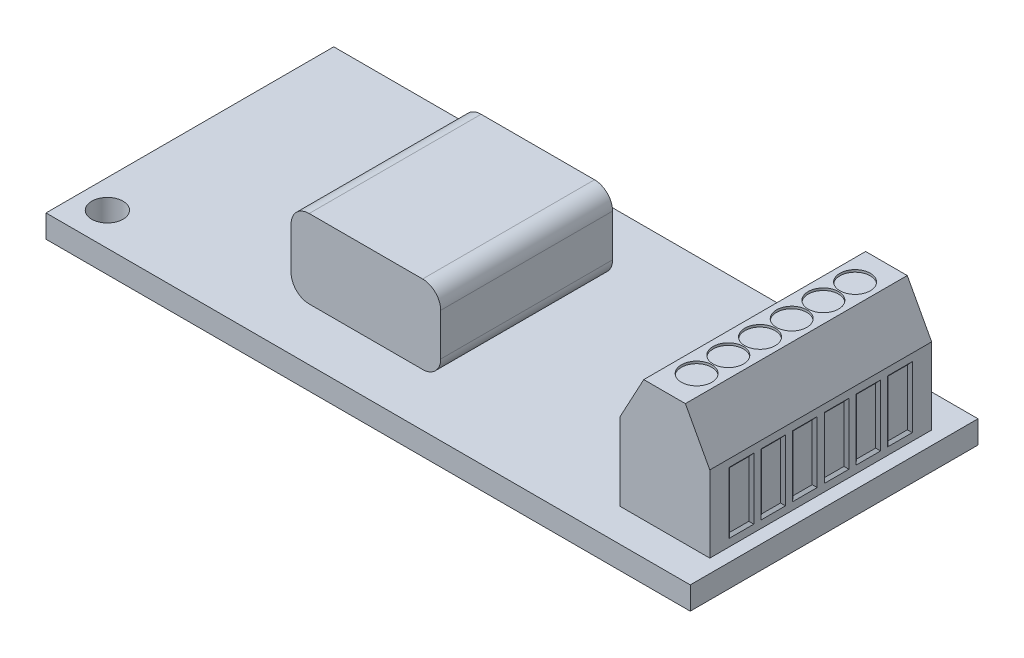
from build123d import *

# Parameters (mm, degrees)
SKETCH1_W           = 45.212
SKETCH1_H           = 20.193
BOSS_EXTRUDE1_DEPTH = 0.8001
SKETCH2_W           = 6.2992
SKETCH2_H           = 15.5702
BOSS_EXTRUDE2_DEPTH = 8.5344
SKETCH6_R           = 1.1
CUT_EXTRUDE4_DEPTH  = 2.6002
SKETCH7_W           = 10.5
SKETCH7_H           = 12.063
BOSS_EXTRUDE3_DEPTH = 5.5
CUT_EXTRUDE5_DEPTH  = 18.8816
SKETCH4_R           = 1.0668
CUT_EXTRUDE6_DEPTH  = 0.15875
SKETCH5_W           = 1.7272
SKETCH5_H           = 4.318
CUT_EXTRUDE7_DEPTH  = 0.15875
CUT_EXTRUDE7_TAPER  = 50
FILLET1_R           = 1.27
SKETCH8_W           = 5
SKETCH8_H           = 5
BOSS_EXTRUDE4_DEPTH = 2.17


with BuildPart() as part:
    # Sketch1 → Boss-Extrude1 (new body, symmetric)
    with BuildSketch(Plane(origin=(0, 0, 0), x_dir=(1, 0, 0), z_dir=(0, 1, 0))):
        Rectangle(SKETCH1_W, SKETCH1_H)
    extrude(amount=BOSS_EXTRUDE1_DEPTH, both=True)

    # Sketch6 → Cut-Extrude4 (cut, through all)
    with BuildSketch(Plane(origin=(0, 0.8001, 0), x_dir=(1, 0, 0), z_dir=(0, 1, 0))):
        with Locations((-20.617, -7.7773)):
            Circle(SKETCH6_R)
        with Locations((11.806, 7.7465)):
            Circle(SKETCH6_R)
    extrude(amount=-CUT_EXTRUDE4_DEPTH, mode=Mode.SUBTRACT)


with BuildPart() as body_2:
    # Sketch2 → Boss-Extrude2 (new body)
    with BuildSketch(Plane(origin=(0, 0.8001, 0), x_dir=(1, 0, 0), z_dir=(0, 1, 0))):
        with Locations((18.5166, 0)):
            Rectangle(SKETCH2_W, SKETCH2_H)
    extrude(amount=BOSS_EXTRUDE2_DEPTH)

    # Sketch3 → Cut-Extrude5 (cut, through all)
    with BuildSketch(Plane.XY.offset(7.7851)):
        Polygon((17.031947663, 9.3345), (19.952947663, 9.3345), (21.6662, 6.1595), (21.6662, 11.226261879), (15.318695326, 11.226261879), (15.318695326, 6.1595), align=None)
    extrude(amount=-CUT_EXTRUDE5_DEPTH, mode=Mode.SUBTRACT)

    # Sketch4 → Cut-Extrude6 (cut)
    with BuildSketch(Plane(origin=(0, 9.3345, 0), x_dir=(1, 0, 0), z_dir=(0, 1, 0))):
        with Locations((18.5166, -5.560785714)):
            Circle(SKETCH4_R)
        with Locations((18.5166, -3.336471429)):
            Circle(SKETCH4_R)
        with Locations((18.5166, -1.112157143)):
            Circle(SKETCH4_R)
        with Locations((18.5166, 1.112157143)):
            Circle(SKETCH4_R)
        with Locations((18.5166, 3.336471429)):
            Circle(SKETCH4_R)
        with Locations((18.5166, 5.560785714)):
            Circle(SKETCH4_R)
    extrude(amount=-CUT_EXTRUDE6_DEPTH, mode=Mode.SUBTRACT)

    # Sketch5 → Cut-Extrude7 (cut)
    with BuildSketch(Plane(origin=(21.6662, 0, 0), x_dir=(0, 0, -1), z_dir=(1, 0, 0))):
        with Locations((-5.560785714, 3.4798)):
            Rectangle(SKETCH5_W, SKETCH5_H)
        with Locations((-3.336471429, 3.4798)):
            Rectangle(SKETCH5_W, SKETCH5_H)
        with Locations((-1.112157143, 3.4798)):
            Rectangle(SKETCH5_W, SKETCH5_H)
        with Locations((1.112157143, 3.4798)):
            Rectangle(SKETCH5_W, SKETCH5_H)
        with Locations((5.560785714, 3.4798)):
            Rectangle(SKETCH5_W, SKETCH5_H)
        with Locations((3.336471429, 3.4798)):
            Rectangle(SKETCH5_W, SKETCH5_H)
    extrude(amount=-CUT_EXTRUDE7_DEPTH, taper=CUT_EXTRUDE7_TAPER, mode=Mode.SUBTRACT)


with BuildPart() as body_3:
    # Sketch7 → Boss-Extrude3 (new body)
    with BuildSketch(Plane(origin=(0, 0.8001, 0), x_dir=(1, 0, 0), z_dir=(0, 1, 0))):
        with Locations((-3.856, -0.365)):
            Rectangle(SKETCH7_W, SKETCH7_H)
    extrude(amount=BOSS_EXTRUDE3_DEPTH)

    # Fillet1
    fillet1_edges = [body_3.edges().sort_by_distance(p)[0] for p in [
        (-9.106, 6.3001, 0.365),
        (1.394, 6.3001, 0.365),
        (-9.106, 0.8001, 0.365),
        (1.394, 0.8001, 0.365),
    ]]
    fillet(fillet1_edges, radius=FILLET1_R)


with BuildPart() as body_4:
    # Sketch8 → Boss-Extrude4 (new body)
    with BuildSketch(Plane.XZ.offset(0.8001)):
        with Locations((6.606, -6.921204961)):
            Rectangle(SKETCH8_W, SKETCH8_H)
    extrude(amount=BOSS_EXTRUDE4_DEPTH)


solid = Compound([part.part, body_2.part, body_3.part, body_4.part])
